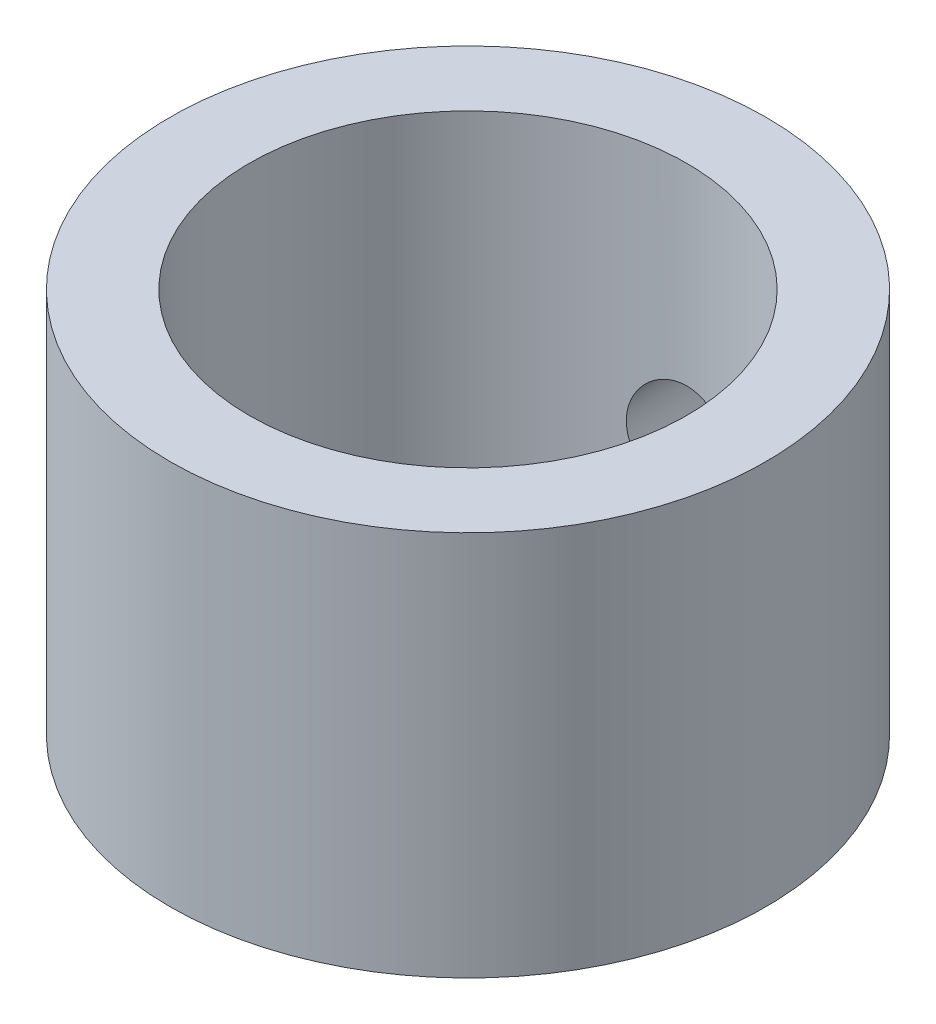
from build123d import *

# Parameters (mm, degrees)
SKETCH1_R           = 9.525
SKETCH1_R_2         = 6.985
BOSS_EXTRUDE1_DEPTH = 4.445
SKETCH3_R           = 9.525
SKETCH3_R_2         = 6.985
BOSS_EXTRUDE2_DEPTH = 6.35
SKETCH2_R           = 1.7145
CUT_EXTRUDE1_DEPTH  = 10.525
SKETCH4_R           = 9.525
SKETCH4_R_2         = 6.985
BOSS_EXTRUDE3_DEPTH = 1.524


with BuildPart() as part:
    # Sketch1 → Boss-Extrude1 (new body)
    with BuildSketch(Plane(origin=(0, 0, 0), x_dir=(1, 0, 0), z_dir=(0, 1, 0))):
        Circle(SKETCH1_R)
        Circle(SKETCH1_R_2, mode=Mode.SUBTRACT)
    extrude(amount=BOSS_EXTRUDE1_DEPTH)

    # Sketch3 → Boss-Extrude2 (add)
    with BuildSketch(Plane(origin=(0, 4.445, 0), x_dir=(1, 0, 0), z_dir=(0, 1, 0))):
        Circle(SKETCH3_R)
        Circle(SKETCH3_R_2, mode=Mode.SUBTRACT)
    extrude(amount=BOSS_EXTRUDE2_DEPTH)

    # Sketch2 → Cut-Extrude1 (cut, through all)
    with BuildSketch(Plane.XY):
        with Locations((0, 4.445)):
            Circle(SKETCH2_R)
    extrude(amount=-CUT_EXTRUDE1_DEPTH, mode=Mode.SUBTRACT)

    # Sketch4 → Boss-Extrude3 (add)
    with BuildSketch(Plane(origin=(0, 10.795, 0), x_dir=(1, 0, 0), z_dir=(0, 1, 0))):
        Circle(SKETCH4_R)
        Circle(SKETCH4_R_2, mode=Mode.SUBTRACT)
    extrude(amount=BOSS_EXTRUDE3_DEPTH)


solid = part.part
